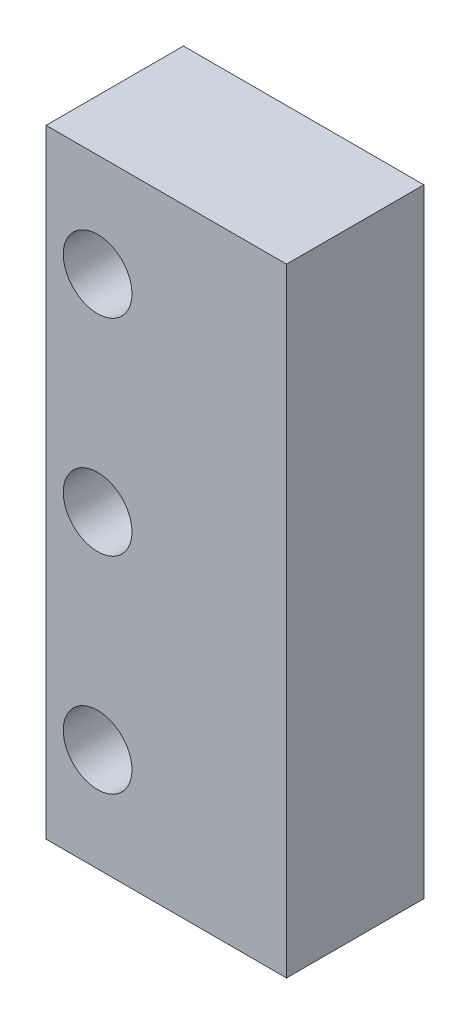
from build123d import *

# Parameters (mm, degrees)
SKETCH1_W                   = 22.225
SKETCH1_H                   = 57.15
BOSS_EXTRUDE1_DEPTH         = 12.7
F_1_4_0_25_DIAMETER_HOLE1_D = 6.35


with BuildPart() as part:
    # Sketch1 → Boss-Extrude1 (new body)
    with BuildSketch(Plane.XY):
        with Locations((-11.1125, 28.575)):
            Rectangle(SKETCH1_W, SKETCH1_H)
    extrude(amount=-BOSS_EXTRUDE1_DEPTH)

    # 1/4 (0.25) Diameter Hole1 (through all)
    with Locations(Plane.XY):
        with Locations((-17.4625, 47.625), (-17.4625, 28.575), (-17.4625, 9.525)):
            Hole(F_1_4_0_25_DIAMETER_HOLE1_D / 2)


solid = part.part
